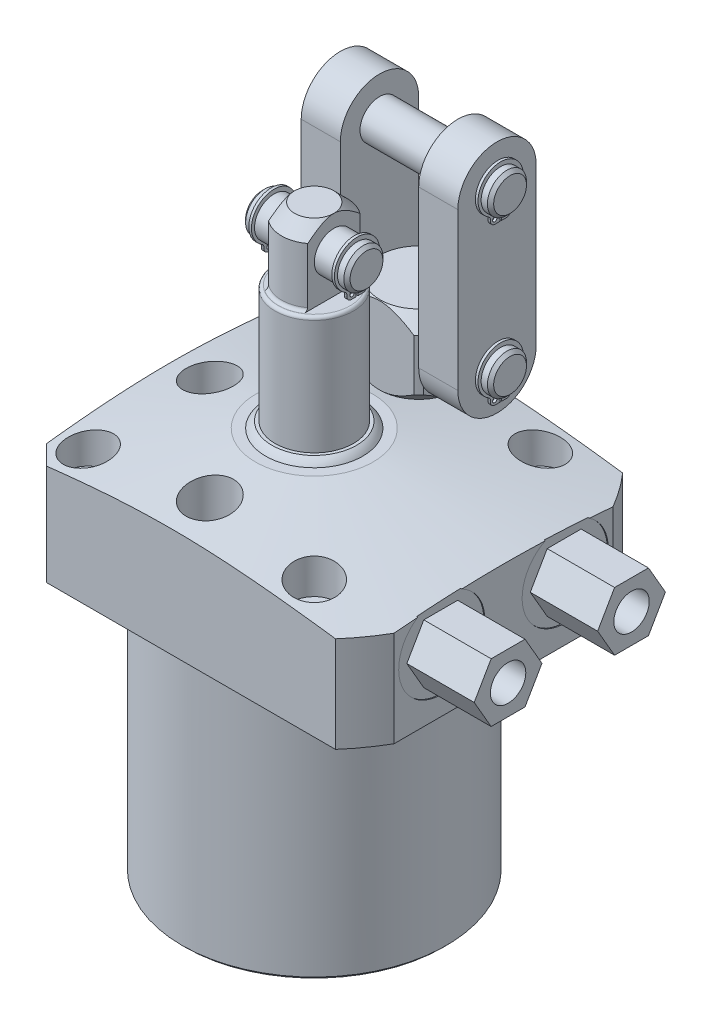
from build123d import *

# Parameters (mm, degrees)
SKETCH3_OUTSIDE_W          = 143.784
SKETCH3_OUTSIDE_H          = 143.784
SKETCH3_OUTSIDE_W_2        = 80.9498
SKETCH3_OUTSIDE_H_2        = 69.85
CUT_EXTRUDE9_DEPTH         = 93.6498
CHAMFER8_SIZE              = 4.7498
CHAMFER5_SIZE              = 0.762
HOLE1_D                    = 7.1374
HOLE1_DEPTH                = 30.1498
HOLE1_CBORE_D              = 11.0998
HOLE1_CBORE_DEPTH          = 11.9126
SKETCH34_R                 = 5.7531
CUT_EXTRUDE10_DEPTH        = 15.875
EXTRUDE14_DEPTH            = 16.383
HOLE2_D                    = 8.6106
HOLE2_DEPTH                = 6.7056
SKETCH33_R                 = 0.889
CUT_EXTRUDE7_DEPTH         = 17.4498
FILLET4_R                  = 0.762
SKETCH29_R                 = 4.75234
EXTRUDE11_DEPTH            = 12.7
EXTRUDE2_START             = -2.286
SKETCH16_R                 = 0.5207
EXTRUDE2_DEPTH             = 0.635
CHAMFER6_SIZE              = 0.762
CUT_EXTRUDE11_REACH        = 114.7
SKETCH30_R                 = 4.75234
EXTRUDE12_DEPTH            = 22.225
EXTRUDE4_START             = -2.286
SKETCH19_R                 = 0.5207
EXTRUDE4_DEPTH             = 0.635
EXTRUDE13_DEPTH            = 9.525
CHAMFER7_SIZE              = 0.762
LPATTERN2_COUNT            = 2
LPATTERN2_PITCH            = 38.1
LPATTERN2_START            = -2.286
LPATTERN2_COPY_1_SKETCH_R  = 0.5207
LPATTERN2_COPY_1_DEPTH     = 0.635
CHAMFER7_OF_LPATTERN2_SIZE = 0.762


with BuildPart() as part:
    # Sketch28 → Revolve7 (revolve)
    with BuildSketch(Plane.XY, mode=Mode.PRIVATE) as revolve7_sk:
        Polygon((-14.2875, 30.1498), (-53.1749, 23.29290217), (-53.1749, 0), (-32.1437, 0), (-32.1437, -63.5), (0, -63.5), (0, 30.1498), align=None)
    revolve(revolve7_sk.sketch.rotate(Axis((0, 0, 0), (0, 1, 0)), 270), axis=Axis((0, 0, 0), (0, 1, 0)))  # turned: the seam where the file's is

    # Sketch3 outside → Cut-Extrude9 (cut)
    with BuildSketch(Plane(origin=(0, 30.1498, 0), x_dir=(-1, 0, 0), z_dir=(0, 1, 0))):
        Rectangle(SKETCH3_OUTSIDE_W, SKETCH3_OUTSIDE_H)
        with Locations((-5.5499, 0)):
            Rectangle(SKETCH3_OUTSIDE_W_2, SKETCH3_OUTSIDE_H_2, mode=Mode.SUBTRACT)
    extrude(amount=-CUT_EXTRUDE9_DEPTH, mode=Mode.SUBTRACT)

    # Chamfer8
    chamfer8_edges = [part.edges().sort_by_distance(p)[0] for p in [
        (-34.925, 11.980016887, -34.925),
        (-34.925, 11.980016887, 34.925),
    ]]
    chamfer(chamfer8_edges, length=CHAMFER8_SIZE)

    # Chamfer5
    chamfer5_edges = [part.edges().sort_by_distance(p)[0] for p in [
        (0, -63.5, 32.1437),
    ]]
    chamfer(chamfer5_edges, length=CHAMFER5_SIZE)

    # Hole1
    with Locations(Plane(origin=(0, 30.1498, 0), x_dir=(-1, 0, 0), z_dir=(0, 1, 0))):
        with Locations((-27.4955, -27.4955), (-27.4955, 27.4955), (27.4955, -27.4955), (27.4955, 27.4955)):
            CounterBoreHole(HOLE1_D / 2, HOLE1_CBORE_D / 2, HOLE1_CBORE_DEPTH, depth=HOLE1_DEPTH)

    # Sketch34 → Cut-Extrude10 (cut)
    with BuildSketch(Plane(origin=(0, 30.1498, 0), x_dir=(1, 0, 0), z_dir=(0, 1, 0))):
        with Locations(Location((0, 25.4, 0), (0, 0, 270))):  # turned: the seam where the file's is
            Circle(SKETCH34_R)
        with Locations(Location((0, -25.4, 0), (0, 0, 135.579018313))):  # turned: the seam where the file's is
            Circle(SKETCH34_R)
        with Locations(Location((-25.4, 0, 0), (0, 0, 270))):  # turned: the seam where the file's is
            Circle(SKETCH34_R)
    extrude(amount=-CUT_EXTRUDE10_DEPTH, mode=Mode.SUBTRACT)

    # S2D0007 → Cut-Revolve2 (revolve, cut)
    with BuildSketch(Plane.XZ.offset(-15.0876)):
        Polygon((46.0248, -15.0114), (46.0248, -25.4889), (45.7708, -25.4889), (45.7708, -21.22805), (43.7007, -20.788036662), (42.902463338, -19.9898), (31.8008, -19.9898), (28.809475494, -15.0114), align=None)
    cut_revolve2 = revolve(axis=Axis((-11.746808274, 15.0876, -15.0114), (-1, 0, 0)), mode=Mode.SUBTRACT)

    # Sketch6 → Cut-Revolve3 (revolve, cut)
    with BuildSketch(Plane.XY.offset(-15.0114), mode=Mode.PRIVATE) as cut_revolve3_sk:
        with BuildLine():
            Line((45.16755, 0), (45.16755, 1.4478))
            Line((45.16755, 1.4478), (42.10705581, 1.4478))
            ThreePointArc((42.10705581, 1.4478), (41.425454622, 0.917608896), (40.64, 0.5588))
            Line((40.64, 0.5588), (39.497, 0.5588))
            Line((39.497, 0.5588), (39.497, 0))
            Line((39.497, 0), (45.16755, 0))
        make_face()
    cut_revolve3 = revolve(cut_revolve3_sk.sketch.rotate(Axis((39.497, -21.049171587, -15.0114), (0, 1, 0)), 90), axis=Axis((39.497, -21.049171587, -15.0114), (0, 1, 0)), mode=Mode.SUBTRACT)  # turned: the seam where the file's is

    # Sketch38 → Extrude14 (add)
    with BuildSketch(Plane(origin=(45.7708, 0, 0), x_dir=(0, 0, -1), z_dir=(1, 0, 0))):
        Polygon((23.252959623, 15.0876), (19.132179811, 22.225), (10.890620189, 22.225), (6.769840377, 15.0876), (10.890620189, 7.9502), (19.132179811, 7.9502), align=None)
    extrude14 = extrude(amount=EXTRUDE14_DEPTH)

    # Hole2
    with Locations(Plane(origin=(62.1538, 0, 0), x_dir=(0, 0, -1), z_dir=(1, 0, 0))):
        with Locations((15.0114, 15.0876)):
            hole2 = Hole(HOLE2_D / 2, depth=HOLE2_DEPTH)

    # Mirror6: Cut-Revolve2, Cut-Revolve3, Extrude14, Hole2 across plane
    add(cut_revolve2.mirror(Plane.XY), mode=Mode.SUBTRACT)
    add(cut_revolve3.mirror(Plane.XY), mode=Mode.SUBTRACT)
    add(extrude14.mirror(Plane.XY))
    add(hole2.mirror(Plane.XY), mode=Mode.SUBTRACT)

    # Sketch12 → Revolve2 (revolve)
    with BuildSketch(Plane(origin=(0, 0, 0), x_dir=(-1, 0, 0), z_dir=(0, 0, -1)), mode=Mode.PRIVATE) as revolve2_sk:
        with BuildLine():
            Line((0, 30.1498), (0, 31.6738))
            Line((0, 31.6738), (10.287, 31.6738))
            ThreePointArc((10.287, 31.6738), (11.136582922, 30.999382922), (11.811, 30.1498))
            Line((11.811, 30.1498), (0, 30.1498))
        make_face()
    revolve(revolve2_sk.sketch.rotate(Axis((0, 22.10562, 0), (0, 1, 0)), 270), axis=Axis((0, 22.10562, 0), (0, 1, 0)))  # turned: the seam where the file's is

    # Sketch13 → Revolve3 (revolve)
    with BuildSketch(Plane.XY, mode=Mode.PRIVATE) as revolve3_sk:
        Polygon((0, 31.6738), (0, 77.7748), (4.7625, 77.7748), (7.9375, 74.5998), (7.9375, 60.325), (9.51865, 60.325), (9.51865, 31.6738), align=None)
    revolve(revolve3_sk.sketch.rotate(Axis((0, 23.02637, 0), (0, 1, 0)), 90), axis=Axis((0, 23.02637, 0), (0, 1, 0)))  # turned: the seam where the file's is

    # Sketch14 → Cut-Extrude7 (cut)
    with BuildSketch(Plane(origin=(0, 77.7748, 0), x_dir=(-1, 0, 0), z_dir=(0, 1, 0))):
        with BuildLine():
            Line((4.7625, 6.35), (4.7625, -6.35))
            ThreePointArc((4.7625, -6.35), (7.9375, 0), (4.7625, 6.35))
        make_face()
        with BuildLine():
            Line((-4.7625, -6.35), (-4.7625, 6.35))
            ThreePointArc((-4.7625, 6.35), (-7.9375, 0), (-4.7625, -6.35))
        make_face()
    extrude(amount=-CUT_EXTRUDE7_DEPTH, mode=Mode.SUBTRACT)

    # Fillet4
    fillet4_edges = [part.edges().sort_by_distance(p)[0] for p in [
        (0, 60.325, 9.51865),
        (0, 60.325, -7.9375),
        (0, 60.325, 7.9375),
    ]]
    fillet(fillet4_edges, radius=FILLET4_R)

    # Sketch29 → Extrude11 (add, symmetric)
    with BuildSketch(Plane.ZY):
        with Locations((0, 69.85)):
            Circle(SKETCH29_R)
    extrude(amount=EXTRUDE11_DEPTH, both=True)

    # Sketch16 → Extrude2 (add)
    with BuildSketch(Plane(origin=(-12.7, 52.3748, 0), x_dir=(0, 0, 1), z_dir=(-1, 0, 0)).offset(EXTRUDE2_START)):
        with BuildLine():
            Line((0.20828, 13.009654613), (0.20828, 10.774454613))
            Line((0.20828, 10.774454613), (1.40208, 10.774454613))
            ThreePointArc((1.40208, 10.774454613), (2.138461002, 11.079473611), (2.44348, 11.815854613))
            Line((2.44348, 11.815854613), (2.44348, 12.16672148))
            ThreePointArc((2.44348, 12.16672148), (2.57349644, 12.670600399), (2.93108124, 13.048663027))
            ThreePointArc((2.93108124, 13.048663027), (0, 23.2283), (-2.93108124, 13.048663027))
            ThreePointArc((-2.93108124, 13.048663027), (-2.57349644, 12.670600399), (-2.44348, 12.16672148))
            Line((-2.44348, 12.16672148), (-2.44348, 11.815854613))
            ThreePointArc((-2.44348, 11.815854613), (-2.138461002, 11.079473611), (-1.40208, 10.774454613))
            Line((-1.40208, 10.774454613), (-0.20828, 10.774454613))
            Line((-0.20828, 10.774454613), (-0.20828, 13.009654613))
            ThreePointArc((-0.20828, 13.009654613), (0, 21.9456), (0.20828, 13.009654613))
        make_face()
        with Locations((1.2446, 11.815854613)):
            Circle(SKETCH16_R, mode=Mode.SUBTRACT)
        with Locations(Location((-1.2446, 11.815854613, 0), (0, 0, 180))):  # turned: the seam where the file's is
            Circle(SKETCH16_R, mode=Mode.SUBTRACT)
    extrude2 = extrude(amount=-EXTRUDE2_DEPTH)

    # Chamfer6
    chamfer6_edges = [part.edges().sort_by_distance(p)[0] for p in [
        (12.7, 69.85, -4.75234),
        (-12.7, 69.85, -4.75234),
    ]]
    chamfer(chamfer6_edges, length=CHAMFER6_SIZE)

    # Mirror2: Extrude2 across plane
    add(extrude2.mirror(Plane.ZY))

    # Sketch35 → Revolve10 (revolve)
    with BuildSketch(Plane.ZY):
        Polygon((-25.4, 14.2748), (-19.05, 14.2748), (-19.05, 30.1498), (-16.002, 30.1498), (-12.7, 33.4518), (-12.7, 45.8978), (-16.002, 49.1998), (-25.4, 49.1998), align=None)
    revolve(axis=Axis((0, 43.57409058, -25.4), (0, -1, 0)))

    # Cut-Extrude11: up to this cone (the profile starts inside it)
    cut_extrude11_end = Plane(origin=(0, 49.1998, -25.4), z_dir=(0, 1, 0)).offset(-28.447999) * Cone(1e-06, 172.096, 172.095999, align=(Align.CENTER, Align.CENTER, Align.MIN), mode=Mode.PRIVATE)
    # Sketch36 → Cut-Extrude11 (cut, up to the surface)
    with BuildSketch(Plane(origin=(0, 49.1998, 0), x_dir=(1, 0, 0), z_dir=(0, 1, 0)), mode=Mode.PRIVATE) as cut_extrude11_sk1:
        with BuildLine():
            Line((9.525, 33.800260413), (9.525, 16.999739587))
            ThreePointArc((9.525, 16.999739587), (12.7, 25.4), (9.525, 33.800260413))
        make_face()
    cut_extrude11_tool1 = extrude(cut_extrude11_sk1.sketch, amount=-CUT_EXTRUDE11_REACH, mode=Mode.PRIVATE) & cut_extrude11_end
    add(cut_extrude11_tool1.solids().sort_by_distance((10.809673, 49.1998, -25.4))[0], mode=Mode.SUBTRACT)
    # Sketch36 → Cut-Extrude11 (cut, up to the surface)
    with BuildSketch(Plane(origin=(0, 49.1998, 0), x_dir=(1, 0, 0), z_dir=(0, 1, 0)), mode=Mode.PRIVATE) as cut_extrude11_sk2:
        with BuildLine():
            Line((8.400260413, 34.925), (-8.400260413, 34.925))
            ThreePointArc((-8.400260413, 34.925), (0, 38.1), (8.400260413, 34.925))
        make_face()
    cut_extrude11_tool2 = extrude(cut_extrude11_sk2.sketch, amount=-CUT_EXTRUDE11_REACH, mode=Mode.PRIVATE) & cut_extrude11_end
    add(cut_extrude11_tool2.solids().sort_by_distance((0, 49.1998, -36.209673))[0], mode=Mode.SUBTRACT)
    # Sketch36 → Cut-Extrude11 (cut, up to the surface)
    with BuildSketch(Plane(origin=(0, 49.1998, 0), x_dir=(1, 0, 0), z_dir=(0, 1, 0)), mode=Mode.PRIVATE) as cut_extrude11_sk3:
        with BuildLine():
            Line((-9.525, 33.800260413), (-9.525, 16.999739587))
            ThreePointArc((-9.525, 16.999739587), (-12.7, 25.4), (-9.525, 33.800260413))
        make_face()
    cut_extrude11_tool3 = extrude(cut_extrude11_sk3.sketch, amount=-CUT_EXTRUDE11_REACH, mode=Mode.PRIVATE) & cut_extrude11_end
    add(cut_extrude11_tool3.solids().sort_by_distance((-10.809673, 49.1998, -25.4))[0], mode=Mode.SUBTRACT)
    # Sketch36 → Cut-Extrude11 (cut, up to the surface)
    with BuildSketch(Plane(origin=(0, 49.1998, 0), x_dir=(1, 0, 0), z_dir=(0, 1, 0)), mode=Mode.PRIVATE) as cut_extrude11_sk4:
        with BuildLine():
            Line((8.400260413, 15.875), (-8.400260413, 15.875))
            ThreePointArc((-8.400260413, 15.875), (0, 12.7), (8.400260413, 15.875))
        make_face()
    cut_extrude11_tool4 = extrude(cut_extrude11_sk4.sketch, amount=-CUT_EXTRUDE11_REACH, mode=Mode.PRIVATE) & cut_extrude11_end
    add(cut_extrude11_tool4.solids().sort_by_distance((0, 49.1998, -14.590327))[0], mode=Mode.SUBTRACT)

    # Sketch30 → Extrude12 (add, symmetric)
    with BuildSketch(Plane.ZY):
        with Locations(Location((-25.4, 39.6748, 0), (0, 0, 270))):  # turned: the seam where the file's is
            Circle(SKETCH30_R)
    extrude12 = extrude(amount=EXTRUDE12_DEPTH, both=True)

    # Sketch19 → Extrude4 (add)
    with BuildSketch(Plane(origin=(-22.225, 11.0998, -22.225), x_dir=(0, 0, 1), z_dir=(-1, 0, 0)).offset(EXTRUDE4_START)):
        with BuildLine():
            Line((-2.96672, 24.109454613), (-2.96672, 21.874254613))
            Line((-2.96672, 21.874254613), (-1.77292, 21.874254613))
            ThreePointArc((-1.77292, 21.874254613), (-1.036538998, 22.179273611), (-0.73152, 22.915654613))
            Line((-0.73152, 22.915654613), (-0.73152, 23.26652148))
            ThreePointArc((-0.73152, 23.26652148), (-0.60150356, 23.770400399), (-0.24391876, 24.148463027))
            ThreePointArc((-0.24391876, 24.148463027), (-3.175, 34.3281), (-6.10608124, 24.148463027))
            ThreePointArc((-6.10608124, 24.148463027), (-5.74849644, 23.770400399), (-5.61848, 23.26652148))
            Line((-5.61848, 23.26652148), (-5.61848, 22.915654613))
            ThreePointArc((-5.61848, 22.915654613), (-5.313461002, 22.179273611), (-4.57708, 21.874254613))
            Line((-4.57708, 21.874254613), (-3.38328, 21.874254613))
            Line((-3.38328, 21.874254613), (-3.38328, 24.109454613))
            ThreePointArc((-3.38328, 24.109454613), (-3.175, 33.0454), (-2.96672, 24.109454613))
        make_face()
        with Locations((-1.72212, 22.915654613)):
            Circle(SKETCH19_R, mode=Mode.SUBTRACT)
        with Locations(Location((-4.62788, 22.915654613, 0), (0, 0, 180))):  # turned: the seam where the file's is
            Circle(SKETCH19_R, mode=Mode.SUBTRACT)
    extrude4 = extrude(amount=-EXTRUDE4_DEPTH)

    # Sketch37 → Extrude13 (add)
    with BuildSketch(Plane.ZY.offset(9.525)):
        with BuildLine():
            Line((-34.924999877, 77.774800031), (-34.925, 39.674800031))
            ThreePointArc((-34.925, 39.674800031), (-25.400000031, 30.1498), (-15.875, 39.674799969))
            Line((-15.875, 39.674799969), (-15.874999877, 77.774799969))
            ThreePointArc((-15.874999877, 77.774799969), (-25.399999847, 87.2998), (-34.924999877, 77.774800031))
        make_face()
    extrude13 = extrude(amount=EXTRUDE13_DEPTH)

    # Mirror3: Extrude4 across plane
    add(extrude4.mirror(Plane.ZY))

    # Chamfer7
    chamfer7_edges = [part.edges().sort_by_distance(p)[0] for p in [
        (22.225, 44.42714, -25.4),
        (-22.225, 44.42714, -25.4),
    ]]
    chamfer(chamfer7_edges, length=CHAMFER7_SIZE)

    # LPattern2: Extrude4, Extrude12 ×2
    with Locations(*[(0, i * LPATTERN2_PITCH, 0) for i in range(1, LPATTERN2_COUNT)]):
        add(extrude4)
        add(extrude12)

    # LPattern2 copy 1 sketch → LPattern2 copy 1 (add)
    with BuildSketch(Plane(origin=(22.225, 49.1998, -22.224999877), x_dir=(0, 0, 1), z_dir=(1, 0, 0)).offset(LPATTERN2_START)):
        with BuildLine():
            Line((-2.96672, -24.109454613), (-2.96672, -21.874254613))
            Line((-2.96672, -21.874254613), (-1.77292, -21.874254613))
            ThreePointArc((-1.77292, -21.874254613), (-1.036538998, -22.179273611), (-0.73152, -22.915654613))
            Line((-0.73152, -22.915654613), (-0.73152, -23.26652148))
            ThreePointArc((-0.73152, -23.26652148), (-0.60150356, -23.770400399), (-0.24391876, -24.148463027))
            ThreePointArc((-0.24391876, -24.148463027), (-3.175, -34.3281), (-6.10608124, -24.148463027))
            ThreePointArc((-6.10608124, -24.148463027), (-5.74849644, -23.770400399), (-5.61848, -23.26652148))
            Line((-5.61848, -23.26652148), (-5.61848, -22.915654613))
            ThreePointArc((-5.61848, -22.915654613), (-5.313461002, -22.179273611), (-4.57708, -21.874254613))
            Line((-4.57708, -21.874254613), (-3.38328, -21.874254613))
            Line((-3.38328, -21.874254613), (-3.38328, -24.109454613))
            ThreePointArc((-3.38328, -24.109454613), (-3.175, -33.0454), (-2.96672, -24.109454613))
        make_face()
        with Locations((-1.72212, -22.915654613)):
            Circle(LPATTERN2_COPY_1_SKETCH_R, mode=Mode.SUBTRACT)
        with Locations((-4.62788, -22.915654613)):
            Circle(LPATTERN2_COPY_1_SKETCH_R, mode=Mode.SUBTRACT)
    extrude(amount=-LPATTERN2_COPY_1_DEPTH)

    # Chamfer7 of LPattern2
    chamfer7_of_lpattern2_edges = [part.edges().sort_by_distance(p)[0] for p in [
        (22.225, 82.52714, -25.399999877),
        (-22.225, 82.52714, -25.399999877),
    ]]
    chamfer(chamfer7_of_lpattern2_edges, length=CHAMFER7_OF_LPATTERN2_SIZE)

    # Mirror8: Extrude13 across plane
    add(extrude13.mirror(Plane.ZY))


with BuildPart() as body_2:
    # Sketch33 → Revolve9 (revolve)
    with BuildSketch(Plane.XY.offset(-15.0114), mode=Mode.PRIVATE) as revolve9_sk:
        with Locations((34.71545, 0.5842)):
            Circle(SKETCH33_R)
    revolve(revolve9_sk.sketch.rotate(Axis((39.497, 8.329668034, -15.0114), (0, -1, 0)), 90), axis=Axis((39.497, 8.329668034, -15.0114), (0, -1, 0)))  # turned: the seam where the file's is


with BuildPart() as body_3:
    # Mirror7: mirrored copy
    add(body_2.part.mirror(Plane.XY))


solid = Compound([part.part, body_2.part, body_3.part])
